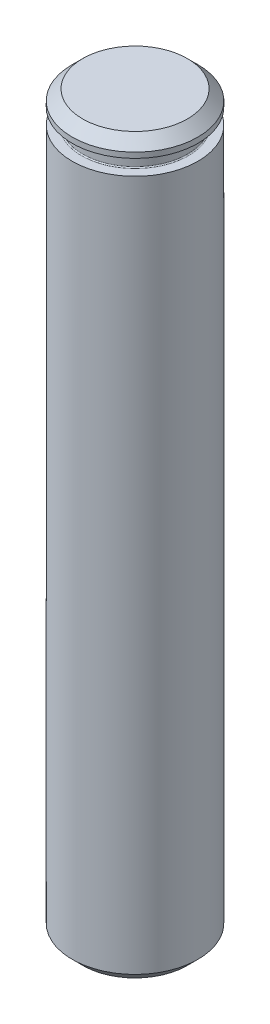
from build123d import *

# Parameters (mm, degrees)
SKETCH1_W     = 3
SKETCH1_H     = 35
CHAMFER1_SIZE = 0.5


with BuildPart() as part:
    # Sketch1 → Revolve1 (revolve)
    with BuildSketch(Plane.XY):
        with Locations((1.5, 17.5)):
            Rectangle(SKETCH1_W, SKETCH1_H)
    revolve(axis=Axis((0, 0, 0), (0, 1, 0)))

    # Sketch3 → Groove for DIN 471 - 4 x 0.4, Circlip for shafts - normal1 (revolve, cut)
    with BuildSketch(Plane(origin=(0, 0, 0), x_dir=(0, 0, -1), z_dir=(-1, 0, 0))):
        with BuildLine():
            Line((2.55, -34.24), (3.6, -34.24))
            Line((3.6, -34.24), (3.6, -33.5))
            Line((3.6, -33.5), (2.55, -33.5))
            ThreePointArc((2.55, -33.5), (2.514644661, -33.514644661), (2.5, -33.55))
            Line((2.5, -33.55), (2.5, -34.19))
            ThreePointArc((2.5, -34.19), (2.514644661, -34.225355339), (2.55, -34.24))
        make_face()
    revolve(axis=Axis((0, 50, 0), (0, -1, 0)), mode=Mode.SUBTRACT)

    # Chamfer1
    chamfer1_edges = [part.edges().sort_by_distance(p)[0] for p in [
        (-3, 0, 0),
        (-3, 35, 0),
    ]]
    chamfer(chamfer1_edges, length=CHAMFER1_SIZE)


solid = part.part
